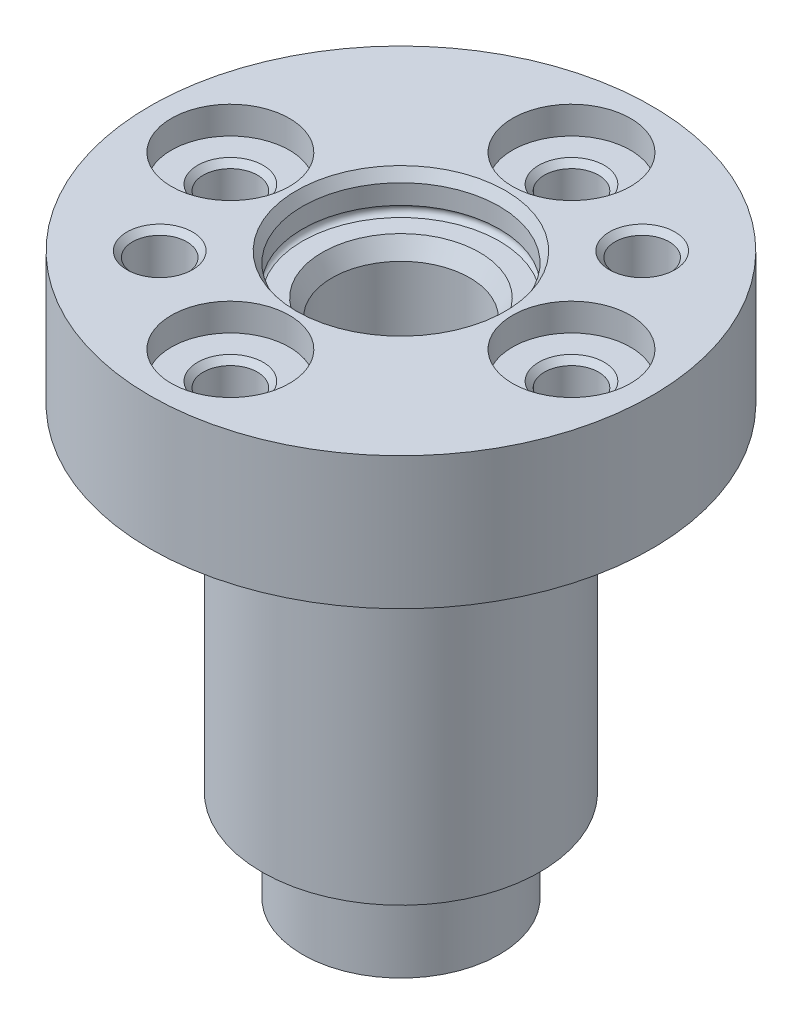
from build123d import *

# Parameters (mm, degrees)
SKETCH2_W                = 17.125
SKETCH2_H                = 5
REVOLVE2_ANGLE           = 4
REVOLVE2_OTHER_WAY_ANGLE = 4


with BuildPart() as part:
    # Sketch1 → Revolve1 (revolve)
    with BuildSketch(Plane.XY):
        Polygon((0, 42.7), (19.125, 42.7), (19.125, 32.6), (10.6, 32.6), (10.6, 7), (7.5, 7), (7.5, 0), (0, 0), align=None)
    revolve(axis=Axis((0, 0, 0), (0, 1, 0)))

    # Sketch2 → Revolve2 (revolve)
    with BuildSketch(Plane(origin=(0, 0, 0), x_dir=(-1, 0, 0), z_dir=(0, 0, -1))):
        with Locations((8.5625, 25.1)):
            Rectangle(SKETCH2_W, SKETCH2_H)
    revolve(axis=Axis((0, 22.6, 0), (0, -1, 0)), revolution_arc=REVOLVE2_ANGLE)

    # Sketch2 → Revolve2 other way (revolve)
    with BuildSketch(Plane(origin=(0, 0, 0), x_dir=(-1, 0, 0), z_dir=(0, 0, -1))):
        with Locations((8.5625, 25.1)):
            Rectangle(SKETCH2_W, SKETCH2_H)
    revolve(axis=Axis((0, 22.6, 0), (0, 1, 0)), revolution_arc=REVOLVE2_OTHER_WAY_ANGLE)

    # Sketch3 → Cut-Revolve1 (revolve, cut)
    with BuildSketch(Plane.XY):
        with BuildLine():
            Line((0, 42.7), (7.965, 42.7))
            Line((7.965, 42.7), (7.5, 41.894596374))
            Line((7.5, 41.894596374), (7.5, 40.4))
            ThreePointArc((7.5, 40.4), (7.8, 40), (7.5, 39.6))
            Line((7.5, 39.6), (6.00055535, 39.6))
            Line((6.00055535, 39.6), (5.25, 38.3))
            Line((5.25, 38.3), (5.25, 1.5))
            Line((5.25, 1.5), (6.116025404, 0))
            Line((6.116025404, 0), (0, 0))
            Line((0, 0), (0, 42.7))
        make_face()
    revolve(axis=Axis((0, 0, 0), (0, 1, 0)), mode=Mode.SUBTRACT)

    # Sketch4 → Cut-Revolve2 (revolve, cut)
    with BuildSketch(Plane.XY):
        Polygon((13, 42.7), (17.5, 42.7), (17.5, 40.6), (15.5, 40.6), (15.067, 40.167), (15.067, 34.6), (13, 33.406616994), align=None)
    revolve(axis=Axis((13, 33.406616994, 0), (0, 1, 0)), mode=Mode.SUBTRACT)

    # Sketch5 → Cut-Revolve3 (revolve, cut)
    with BuildSketch(Plane.XY):
        Polygon((-13, 42.7), (-8.5, 42.7), (-8.5, 40.6), (-10.5, 40.6), (-10.933, 40.167), (-10.933, 34.6), (-13, 33.406616994), align=None)
    revolve(axis=Axis((-13, 33.406616994, 0), (0, 1, 0)), mode=Mode.SUBTRACT)

    # Sketch6 → Cut-Revolve4 (revolve, cut)
    with BuildSketch(Plane(origin=(0, 0, 0), x_dir=(0, 0, -1), z_dir=(1, 0, 0))):
        Polygon((13, 42.7), (17.5, 42.7), (17.5, 40.6), (15.5, 40.6), (15.067, 40.167), (15.067, 34.6), (13, 33.406616994), align=None)
    revolve(axis=Axis((0, 33.406616994, -13), (0, 1, 0)), mode=Mode.SUBTRACT)

    # Sketch7 → Cut-Revolve5 (revolve, cut)
    with BuildSketch(Plane(origin=(0, 0, 0), x_dir=(0, 0, -1), z_dir=(1, 0, 0))):
        Polygon((-13, 42.7), (-8.5, 42.7), (-8.5, 40.6), (-10.5, 40.6), (-10.933, 40.167), (-10.933, 34.6), (-13, 33.406616994), align=None)
    revolve(axis=Axis((0, 33.406616994, 13), (0, 1, 0)), mode=Mode.SUBTRACT)

    # Sketch8 → Cut-Revolve6 (revolve, cut)
    with BuildSketch(Plane(origin=(0, 0, 0), x_dir=(0.7071067811865475, 0, -0.7071067811865477), z_dir=(0.7071067811865477, 0, 0.7071067811865475))):
        Polygon((13, 42.7), (15.5, 42.7), (15.067, 42.267), (15.067, 34.6), (13, 33.406616994), align=None)
    revolve(axis=Axis((9.192388155, 33.406616994, -9.192388155), (0, 1, 0)), mode=Mode.SUBTRACT)

    # Sketch9 → Cut-Revolve7 (revolve, cut)
    with BuildSketch(Plane(origin=(0, 0, 0), x_dir=(0.7071067811865475, 0, -0.7071067811865477), z_dir=(0.7071067811865477, 0, 0.7071067811865475))):
        Polygon((-13, 42.7), (-10.5, 42.7), (-10.933, 42.267), (-10.933, 34.6), (-13, 33.406616994), align=None)
    revolve(axis=Axis((-9.192388155, 33.406616994, 9.192388155), (0, 1, 0)), mode=Mode.SUBTRACT)


solid = part.part
